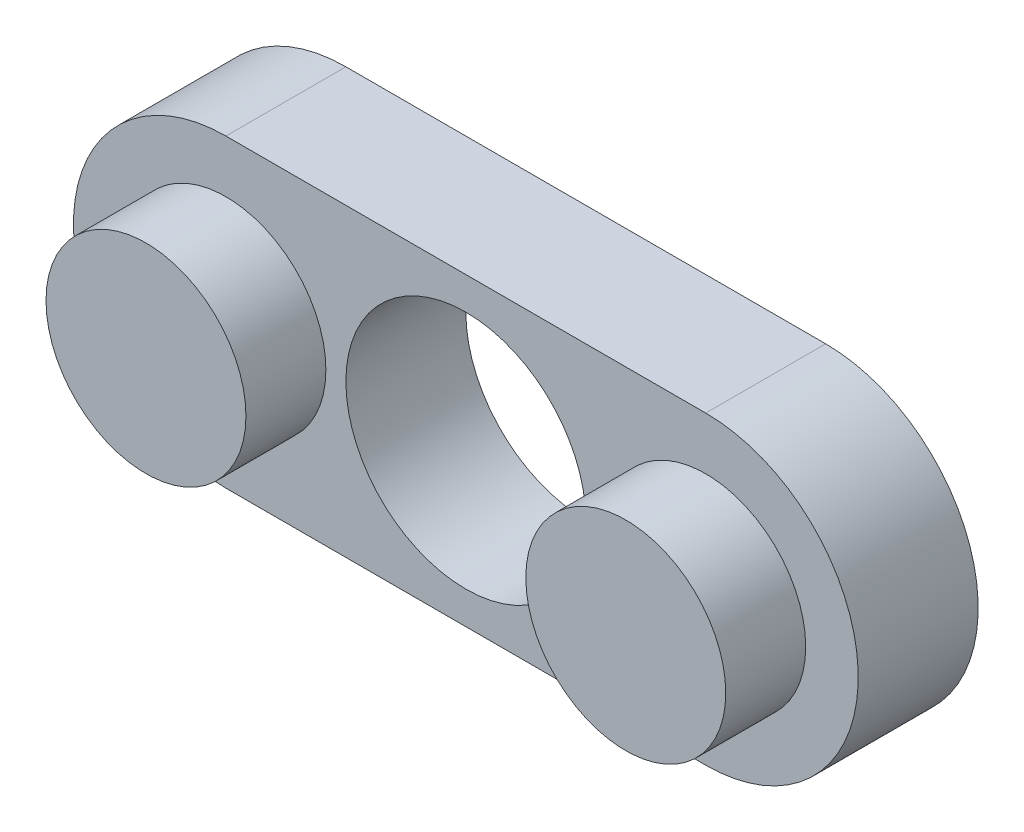
from build123d import *

# Parameters (mm, degrees)
SKETCH1_R                  = 2.5
BOSS_EXTRUDE1_DEPTH        = 3
SKETCH1_2_R                = 2.5
BOSS_EXTRUDE2_DEPTH        = 2
BOSS_EXTRUDE2_DEPTH_BACK   = 3
BOSS_EXTRUDE2_2_DEPTH      = 2
BOSS_EXTRUDE2_2_DEPTH_BACK = 3
SKETCH2_R                  = 3
CUT_EXTRUDE1_DEPTH         = 6


with BuildPart() as part:
    # Sketch1 → Boss-Extrude1 (new body)
    with BuildSketch(Plane.XY):
        with BuildLine():
            Line((0, 3.813559322), (12, 3.813559322))
            ThreePointArc((12, 3.813559322), (15.813559322, 0), (12, -3.813559322))
            Line((12, -3.813559322), (0, -3.813559322))
            ThreePointArc((0, -3.813559322), (-3.813559322, 0), (0, 3.813559322))
        make_face()
        Circle(SKETCH1_R, mode=Mode.SUBTRACT)
        with Locations((12, 0)):
            Circle(SKETCH1_R, mode=Mode.SUBTRACT)
    extrude(amount=-BOSS_EXTRUDE1_DEPTH)

    # Sketch2 → Cut-Extrude1 (cut, through all)
    with BuildSketch(Plane(origin=(0, 0, -3), x_dir=(-1, 0, 0), z_dir=(0, 0, -1))):
        with Locations((-6, 0)):
            Circle(SKETCH2_R)
    extrude(amount=-CUT_EXTRUDE1_DEPTH, mode=Mode.SUBTRACT)


with BuildPart() as body_2:
    # Sketch1_2 → Boss-Extrude2 (new body, two sides)
    with BuildSketch(Plane.XY) as boss_extrude2_sk:
        Circle(SKETCH1_2_R)
    extrude(amount=BOSS_EXTRUDE2_DEPTH)
    extrude(boss_extrude2_sk.sketch, amount=-BOSS_EXTRUDE2_DEPTH_BACK)


with BuildPart() as body_3:
    # Sketch1_2 → Boss-Extrude2 2 (new body, two sides)
    with BuildSketch(Plane.XY) as boss_extrude2_2_sk:
        with Locations((12, 0)):
            Circle(SKETCH1_2_R)
    extrude(amount=BOSS_EXTRUDE2_2_DEPTH)
    extrude(boss_extrude2_2_sk.sketch, amount=-BOSS_EXTRUDE2_2_DEPTH_BACK)


solid = Compound([part.part, body_2.part, body_3.part])
